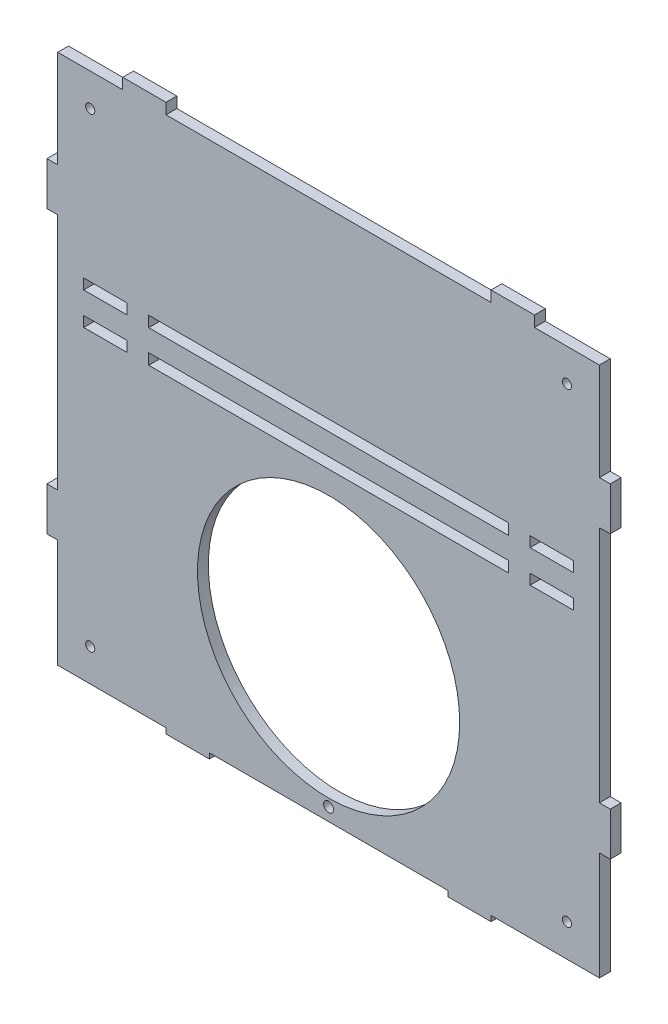
from build123d import *

# Parameters (mm, degrees)
SKETCH1_R           = 60.5
SKETCH1_R_2         = 2.3
BOSS_EXTRUDE1_DEPTH = 5
SKETCH3_W           = 20
SKETCH3_H           = 4.8
CUT_EXTRUDE1_DEPTH  = 5
SKETCH4_W           = 165.999999998
SKETCH4_H           = 5
CUT_EXTRUDE2_DEPTH  = 5
SKETCH5_R           = 2.1
CUT_EXTRUDE3_DEPTH  = 5
SKETCH6_W           = 30
SKETCH6_H           = 5
SKETCH6_W_2         = 150
CUT_EXTRUDE4_DEPTH  = 5
SKETCH7_R           = 2.1
CUT_EXTRUDE5_DEPTH  = 5


with BuildPart() as part:
    # Sketch1 → Boss-Extrude1 (new body)
    with BuildSketch(Plane.XY):
        Polygon((125.000000001, -69.9), (75.000000001, -69.9), (75.000000001, -72.4), (55.000000001, -72.4), (55.000000001, -69.9), (-54.999999999, -69.9), (-54.999999999, -72.4), (-74.999999999, -72.4), (-74.999999999, -69.9), (-124.999999999, -69.9), (-124.999999999, -19.9), (-129.999999999, -19.9), (-129.999999999, 0.1), (-124.999999999, 0.1), (-124.999999999, 110.1), (-129.999999999, 110.1), (-129.999999999, 130.1), (-124.999999999, 130.1), (-124.999999999, 180.1), (125.000000001, 180.1), (125.000000001, 130.1), (130.000000001, 130.1), (130.000000001, 110.1), (125.000000001, 110.1), (125.000000001, 0.1), (130.000000001, 0.1), (130.000000001, -19.9), (125.000000001, -19.9), align=None)
        Circle(SKETCH1_R, mode=Mode.SUBTRACT)
        with Locations((0, -64)):
            Circle(SKETCH1_R_2, mode=Mode.SUBTRACT)
    extrude(amount=BOSS_EXTRUDE1_DEPTH)

    # Sketch3 → Cut-Extrude1 (cut)
    with BuildSketch(Plane.XY.offset(5)):
        with Locations((-102.999999999, 88.505234687)):
            Rectangle(SKETCH3_W, SKETCH3_H)
        with Locations((-102.999999999, 73.505234687)):
            Rectangle(SKETCH3_W, SKETCH3_H)
    cut_extrude1 = extrude(amount=-CUT_EXTRUDE1_DEPTH, mode=Mode.SUBTRACT)

    # Mirror1: Cut-Extrude1 across plane
    add(cut_extrude1.mirror(Plane(origin=(0, 0, 0), x_dir=(0, 0, 1), z_dir=(1, 0, 0))), mode=Mode.SUBTRACT)

    # Sketch4 → Cut-Extrude2 (cut)
    with BuildSketch(Plane.XY.offset(5)):
        with Locations((0, 88.505234687)):
            Rectangle(SKETCH4_W, SKETCH4_H)
        with Locations((0, 73.505234687)):
            Rectangle(SKETCH4_W, SKETCH4_H)
    extrude(amount=-CUT_EXTRUDE2_DEPTH, mode=Mode.SUBTRACT)

    # Sketch5 → Cut-Extrude3 (cut)
    with BuildSketch(Plane.XY.offset(5)):
        with Locations((-109.999999999, -54.9)):
            Circle(SKETCH5_R)
        with Locations((110.000000001, -54.9)):
            Circle(SKETCH5_R)
    extrude(amount=-CUT_EXTRUDE3_DEPTH, mode=Mode.SUBTRACT)

    # Sketch6 → Cut-Extrude4 (cut)
    with BuildSketch(Plane.XY.offset(5)):
        with Locations((-109.999999999, 177.6)):
            Rectangle(SKETCH6_W, SKETCH6_H)
        with Locations((1e-09, 177.6)):
            Rectangle(SKETCH6_W_2, SKETCH6_H)
        with Locations((110.000000001, 177.6)):
            Rectangle(SKETCH6_W, SKETCH6_H)
    extrude(amount=-CUT_EXTRUDE4_DEPTH, mode=Mode.SUBTRACT)

    # Sketch7 → Cut-Extrude5 (cut)
    with BuildSketch(Plane.XY.offset(5)):
        with Locations((-109.999999999, 160.1)):
            Circle(SKETCH7_R)
        with Locations((110.000000001, 160.1)):
            Circle(SKETCH7_R)
    extrude(amount=-CUT_EXTRUDE5_DEPTH, mode=Mode.SUBTRACT)


solid = part.part
